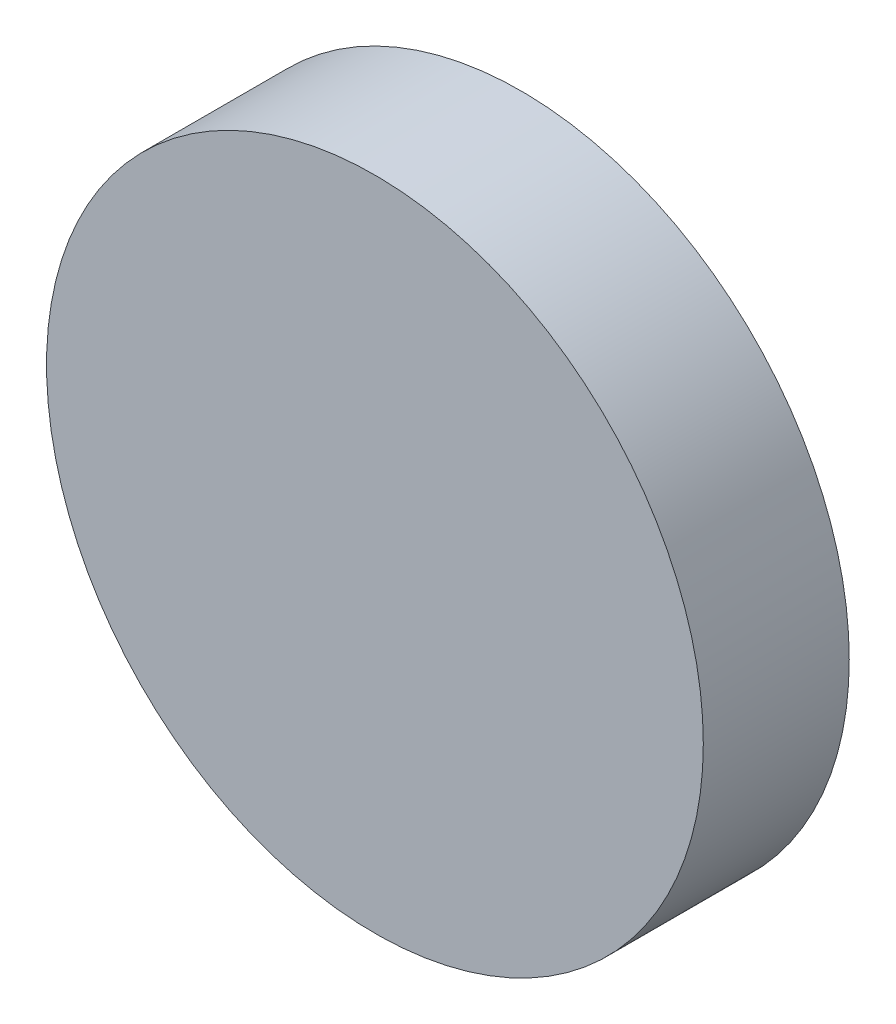
from build123d import *

# Parameters (mm, degrees)
SKETCH_1_R      = 22.5
EXTRUDE_1_DEPTH = 10


with BuildPart() as part:
    # 草图1 → 凸台-拉伸1 (new body)
    with BuildSketch(Plane.XY):
        with Locations((-10.515542641, 10.315880439)):
            Circle(SKETCH_1_R)
    extrude(amount=EXTRUDE_1_DEPTH)


solid = part.part
